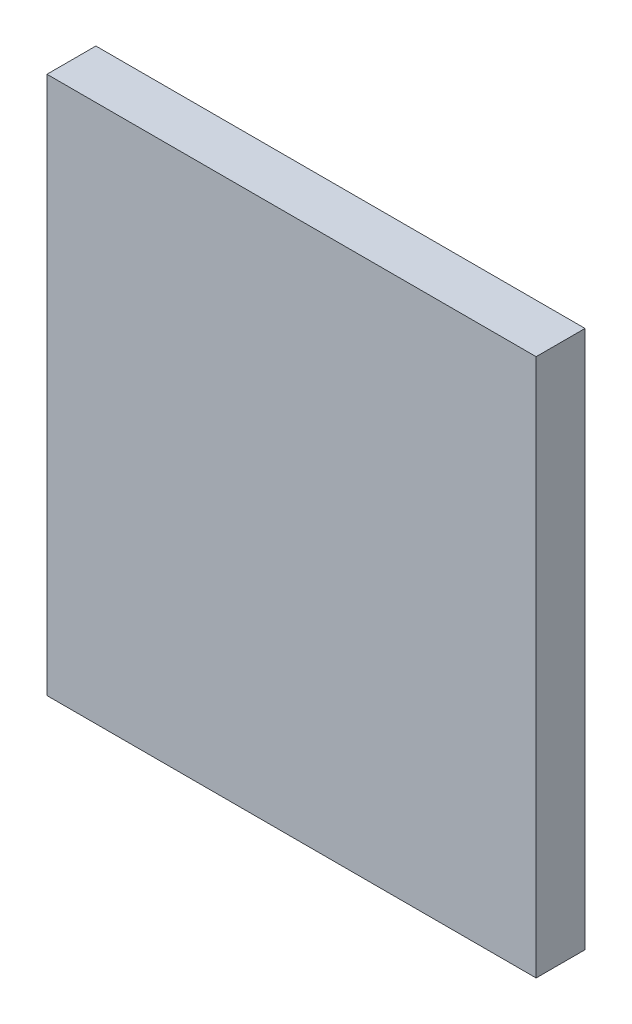
from build123d import *

# Parameters (mm, degrees)
SKETCH_1_W      = 30
SKETCH_1_H      = 33
EXTRUDE_1_DEPTH = 3


with BuildPart() as part:
    # 草图1 → 凸台-拉伸1 (new body)
    with BuildSketch(Plane.XY):
        with Locations((-15, 0)):
            Rectangle(SKETCH_1_W, SKETCH_1_H)
    extrude(amount=EXTRUDE_1_DEPTH)


solid = part.part
